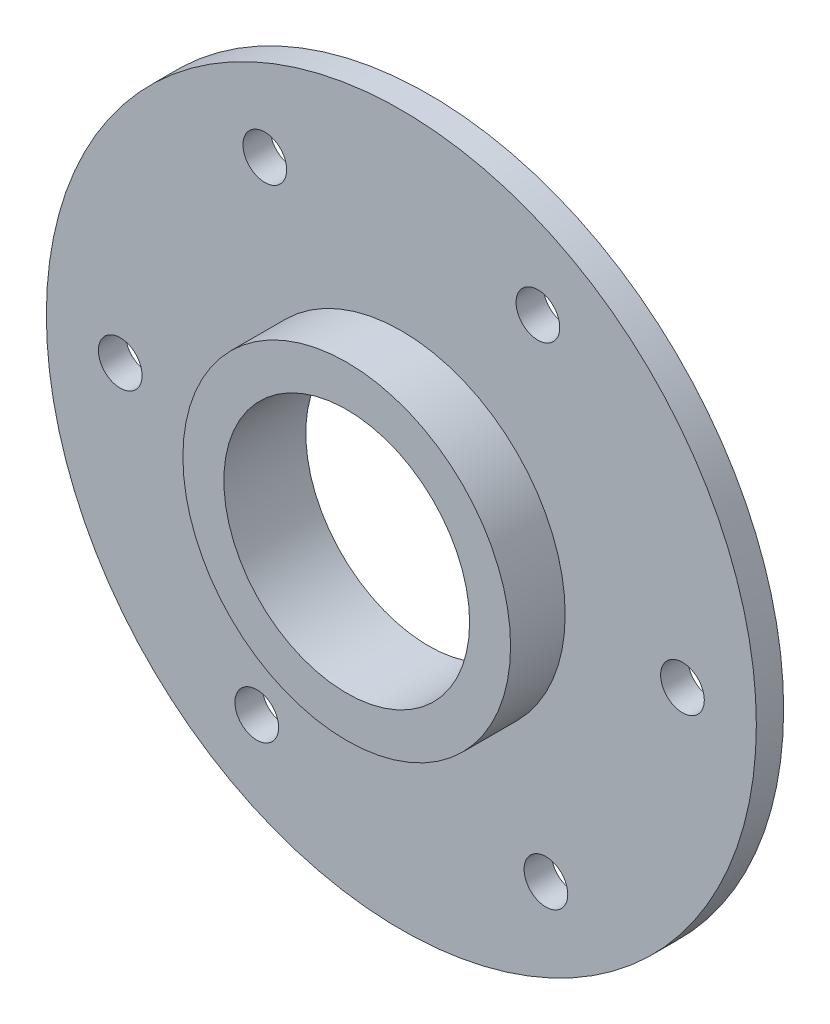
from build123d import *

# Parameters (mm, degrees)
SKETCH1_R           = 65
BOSS_EXTRUDE1_DEPTH = 5
SKETCH11_R          = 4
CUT_EXTRUDE1_DEPTH  = 10
SKETCH12_R          = 30
BOSS_EXTRUDE2_DEPTH = 10
SKETCH13_R          = 22.5
CUT_EXTRUDE2_DEPTH  = 16


with BuildPart() as part:
    # Sketch1 → Boss-Extrude1 (new body)
    with BuildSketch(Plane.XY.offset(5)):
        Circle(SKETCH1_R)
    extrude(amount=-BOSS_EXTRUDE1_DEPTH)

    # Sketch11 → Cut-Extrude1 (cut)
    with BuildSketch(Plane.XY.offset(5)):
        with Locations((-25, 45)):
            Circle(SKETCH11_R)
        with Locations((25, 45)):
            Circle(SKETCH11_R)
        with Locations((26.47114317, -44.150635095)):
            Circle(SKETCH11_R)
        with Locations((51.47114317, -0.849364905)):
            Circle(SKETCH11_R)
        with Locations((-51.47114317, -0.849364905)):
            Circle(SKETCH11_R)
        with Locations((-26.47114317, -44.150635095)):
            Circle(SKETCH11_R)
    extrude(amount=-CUT_EXTRUDE1_DEPTH, mode=Mode.SUBTRACT)

    # Sketch12 → Boss-Extrude2 (add)
    with BuildSketch(Plane.XY.offset(5)):
        Circle(SKETCH12_R)
    extrude(amount=BOSS_EXTRUDE2_DEPTH)

    # Sketch13 → Cut-Extrude2 (cut, through all)
    with BuildSketch(Plane.XY.offset(15)):
        Circle(SKETCH13_R)
    extrude(amount=-CUT_EXTRUDE2_DEPTH, mode=Mode.SUBTRACT)


solid = part.part
